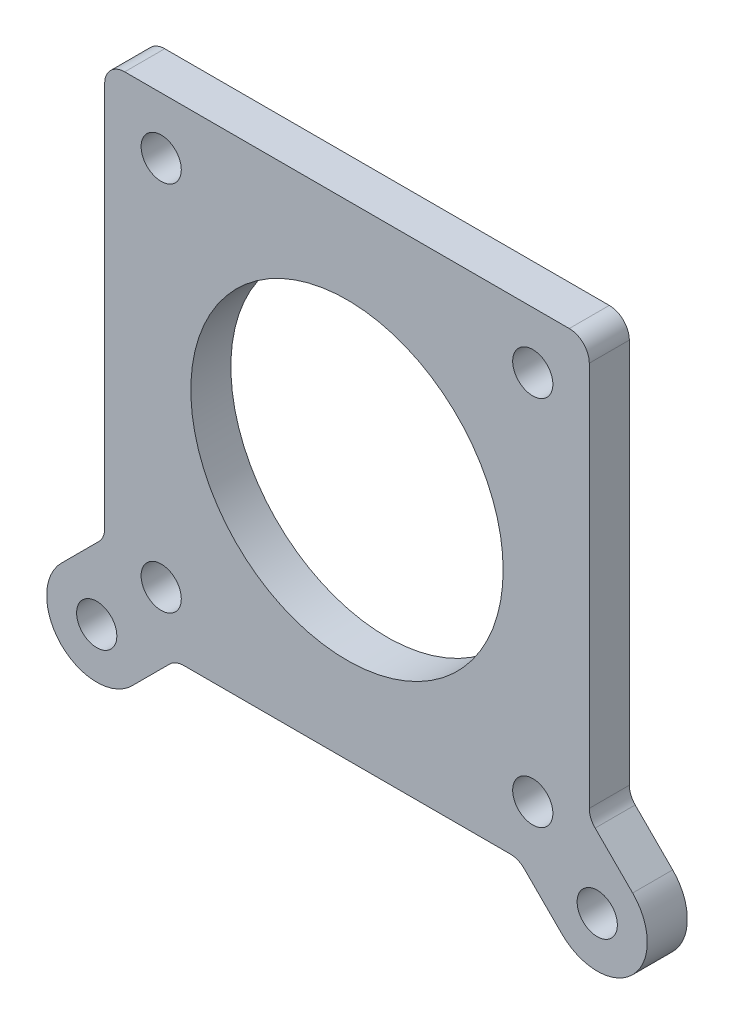
from build123d import *

# Parameters (mm, degrees)
SKETCH1_W              = 61.48
SKETCH1_H              = 61.48
SKETCH1_R              = 2.55
SKETCH1_R_2            = 19.812
BOSS_EXTRUDE1_DEPTH    = 5.08
FILLET1_R              = 2.54
BOSS_EXTRUDE2_DEPTH    = 5.08
FILLET2_R              = 2.54
F_10_CLEARANCE_HOLE1_D = 5.1054


with BuildPart() as part:
    # Sketch1 → Boss-Extrude1 (new body)
    with BuildSketch(Plane.XY):
        Rectangle(SKETCH1_W, SKETCH1_H)
        with Locations((-23.570000148, 23.570000149)):
            Circle(SKETCH1_R, mode=Mode.SUBTRACT)
        with Locations((23.569999852, 23.570000149)):
            Circle(SKETCH1_R, mode=Mode.SUBTRACT)
        with Locations((23.569999852, -23.569999851)):
            Circle(SKETCH1_R, mode=Mode.SUBTRACT)
        with Locations((-23.570000148, -23.569999851)):
            Circle(SKETCH1_R, mode=Mode.SUBTRACT)
        with Locations((-1.48e-07, 1.49e-07)):
            Circle(SKETCH1_R_2, mode=Mode.SUBTRACT)
    extrude(amount=-BOSS_EXTRUDE1_DEPTH)

    # Fillet1
    fillet1_edges = [part.edges().sort_by_distance(p)[0] for p in [
        (-30.74, 30.74, -2.54),
        (30.74, 30.74, -2.54),
        (30.74, -30.74, -2.54),
        (-30.74, -30.74, -2.54),
    ]]
    fillet(fillet1_edges, radius=FILLET1_R)

    # Sketch7 → Boss-Extrude2 (add, through all)
    with BuildSketch(Plane.XY):
        with BuildLine():
            Line((-27.259871939, -36.240128061), (-21.759743879, -30.74))
            Line((-21.759743879, -30.74), (-30.74, -21.759743879))
            Line((-30.74, -21.759743879), (-36.240128061, -27.259871939))
            ThreePointArc((-36.240128061, -27.259871939), (-36.240128061, -36.240128061), (-27.259871939, -36.240128061))
        make_face()
        with BuildLine():
            Line((30.74, -21.759743879), (21.759743879, -30.74))
            Line((21.759743879, -30.74), (27.259871939, -36.240128061))
            ThreePointArc((27.259871939, -36.240128061), (36.240128061, -36.240128061), (36.240128061, -27.259871939))
            Line((36.240128061, -27.259871939), (30.74, -21.759743879))
        make_face()
    extrude(amount=-BOSS_EXTRUDE2_DEPTH)

    # Fillet2
    fillet2_edges = [part.edges().sort_by_distance(p)[0] for p in [
        (-30.74, -21.759743879, -2.54),
        (-21.759743879, -30.74, -2.54),
        (21.759743879, -30.74, -2.54),
        (30.74, -21.759743879, -2.54),
    ]]
    fillet(fillet2_edges, radius=FILLET2_R)

    # #10 Clearance Hole1 (through all)
    with Locations(Plane.XY):
        with Locations((-31.75, -31.75), (31.75, -31.75)):
            Hole(F_10_CLEARANCE_HOLE1_D / 2)


solid = part.part
